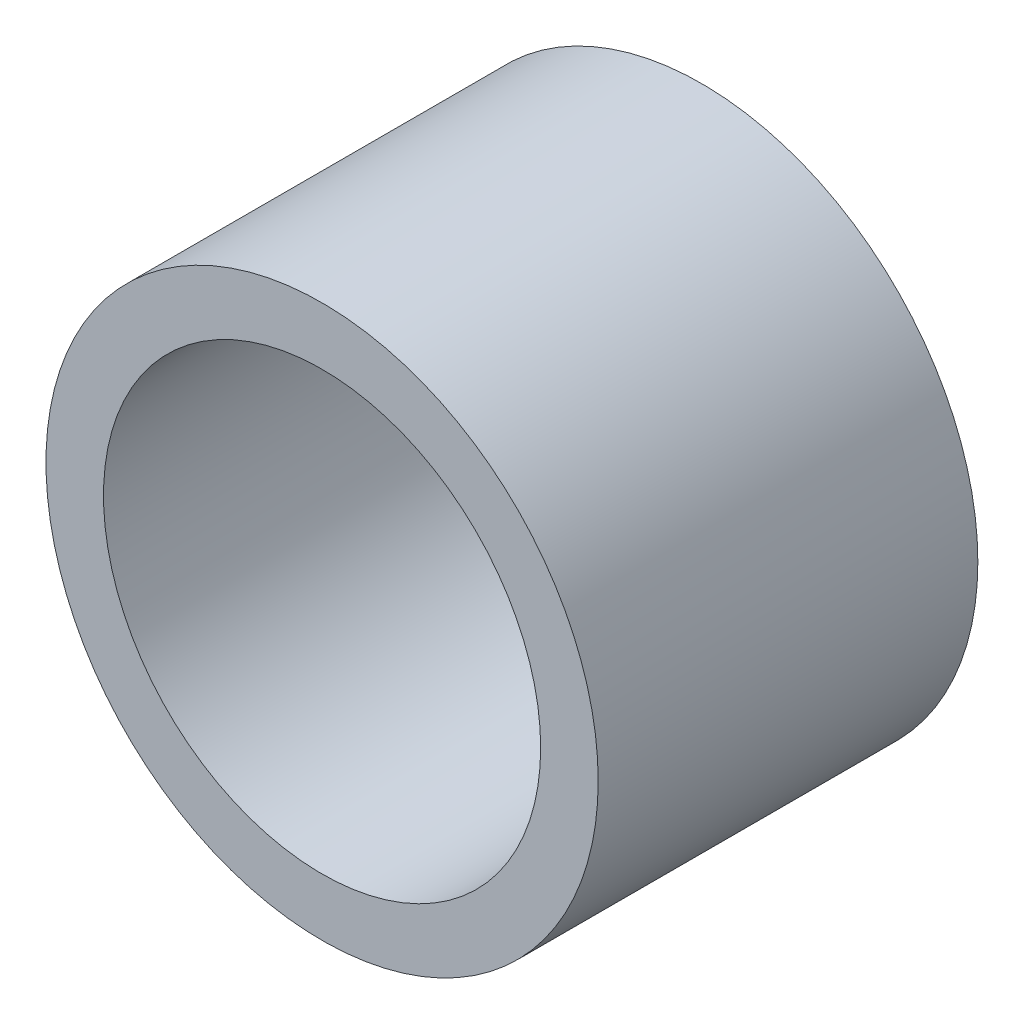
from build123d import *

# Parameters (mm, degrees)
SKETCH1_R           = 12
SKETCH1_R_2         = 9.5
BOSS_EXTRUDE1_DEPTH = 16.5
SCALE1_SCALE        = 0.75
SCALE2_SCALE        = 0.85


with BuildPart() as part:
    # Sketch1 → Boss-Extrude1 (new body)
    with BuildSketch(Plane(origin=(0, 0, 0), x_dir=(0, 1, 0), z_dir=(0, 0, 1))):
        Circle(SKETCH1_R)
        Circle(SKETCH1_R_2, mode=Mode.SUBTRACT)
    extrude(amount=BOSS_EXTRUDE1_DEPTH)


with BuildPart() as part_1:
    # Scale1: scaled about (0, 0, 8.25)
    add(part.part.scale(SCALE1_SCALE).moved(Location((0, 0, 2.0625))))


with BuildPart() as part_2:
    # Scale2: scaled about (0, 0, 8.25)
    add(part_1.part.scale(SCALE2_SCALE).moved(Location((0, 0, 1.2375))))


solid = part_2.part
